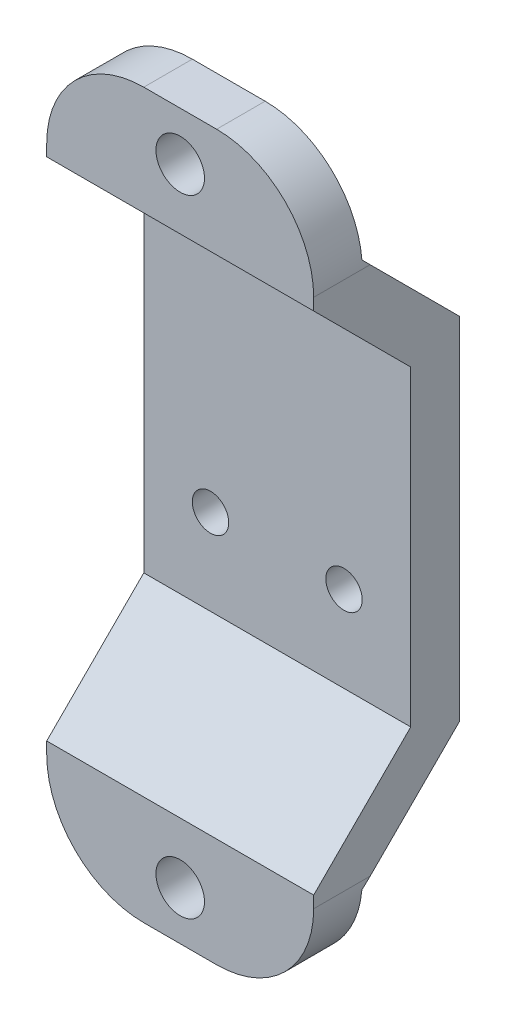
from build123d import *

# Parameters (mm, degrees)
BOSS_EXTRUDE1_DEPTH      = 8.87222
BOSS_EXTRUDE1_DEPTH_BACK = 8.87222
SKETCH2_R                = 1.6129
CUT_EXTRUDE1_DEPTH       = 28.401304094
SKETCH3_R                = 1.20904
CUT_EXTRUDE2_DEPTH       = 27.434873517
FILLET1_R                = 6.4516


with BuildPart() as part:
    # Sketch1 → Boss-Extrude1 (new, two sides: drawn at the far end of the back side and taken through both)
    with BuildSketch(Plane(origin=(0, 0, 0), x_dir=(0, 0, -1), z_dir=(1, 0, 0)).offset(-BOSS_EXTRUDE1_DEPTH_BACK)):
        Polygon((-4.8387, 24.05126), (-1.6129, 24.05126), (-1.6129, 18.12798), (4.8387, 11.67638), (4.8387, -11.67638), (-1.6129, -18.12798), (-1.6129, -24.05126), (-4.8387, -24.05126), (-4.8387, -16.81226), (1.6129, -10.36066), (1.6129, 10.36066), (-4.8387, 16.81226), align=None)
    extrude(amount=BOSS_EXTRUDE1_DEPTH + BOSS_EXTRUDE1_DEPTH_BACK)

    # Sketch2 → Cut-Extrude1 (cut, through all)
    with BuildSketch(Plane.XY.offset(4.8387)):
        with Locations((0, 20.82546)):
            Circle(SKETCH2_R)
    cut_extrude1 = extrude(amount=-CUT_EXTRUDE1_DEPTH, mode=Mode.SUBTRACT)

    # Mirror1: Cut-Extrude1 across plane
    add(cut_extrude1.mirror(Plane.ZX), mode=Mode.SUBTRACT)

    # Sketch3 → Cut-Extrude2 (cut, through all)
    with BuildSketch(Plane.XY.offset(-1.6129)):
        with Locations((-4.43611, -4.65328)):
            Circle(SKETCH3_R)
        with Locations((4.43611, -4.65328)):
            Circle(SKETCH3_R)
    extrude(amount=-CUT_EXTRUDE2_DEPTH, mode=Mode.SUBTRACT)

    # Fillet1
    fillet1_edges = [part.edges().sort_by_distance(p)[0] for p in [
        (-8.87222, -24.05126, 3.2258),
        (8.87222, -24.05126, 3.2258),
        (8.87222, 24.05126, 3.2258),
        (-8.87222, 24.05126, 3.2258),
    ]]
    fillet(fillet1_edges, radius=FILLET1_R)


solid = part.part
